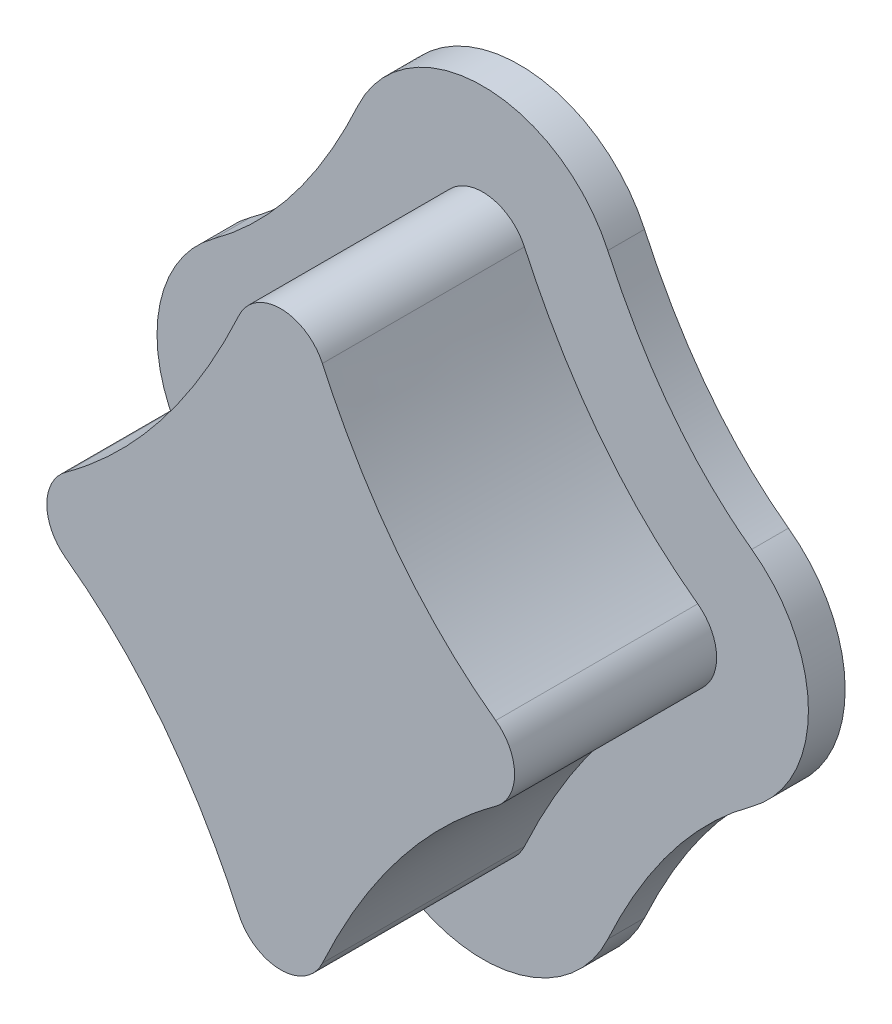
from build123d import *

# Parameters (mm, degrees)
BOSS_EXTRUDE1_DEPTH = 2.6
FILLET1_R           = 0.5
BOSS_EXTRUDE2_DEPTH = 0.4


with BuildPart() as part:
    # Sketch4 → Boss-Extrude1 (new body)
    with BuildSketch(Plane.XY):
        with BuildLine():
            add(Edge.make_bspline(
                [(0, 4), (0.515028324, 2.414905806), (1.36313107, 0.834026377), (3, 0)],
                knots=[0, 0, 0, 0, 1, 1, 1, 1], degree=3))
            add(Edge.make_bspline(
                [(0, -4), (0.515028324, -2.414905806), (1.36313107, -0.834026377), (3, 0)],
                knots=[0, 0, 0, 0, 1, 1, 1, 1], degree=3))
            add(Edge.make_bspline(
                [(0, -4), (-0.515028324, -2.414905806), (-1.36313107, -0.834026377), (-3, 0)],
                knots=[0, 0, 0, 0, 1, 1, 1, 1], degree=3))
            add(Edge.make_bspline(
                [(0, 4), (-0.515028324, 2.414905806), (-1.36313107, 0.834026377), (-3, 0)],
                knots=[0, 0, 0, 0, 1, 1, 1, 1], degree=3))
        make_face()
    extrude(amount=BOSS_EXTRUDE1_DEPTH)

    # Fillet1
    fillet1_edges = [part.edges().sort_by_distance(p)[0] for p in [
        (0, -4, 1.3),
        (-3, 0, 1.3),
        (3, 0, 1.3),
        (0, 4, 1.3),
    ]]
    fillet(fillet1_edges, radius=FILLET1_R)

    # Sketch5 → Boss-Extrude2 (add)
    with BuildSketch(Plane.XY):
        with BuildLine():
            ThreePointArc((-2.929739435, 1.212558746), (-3.546732478, 0), (-2.929739435, -1.212558746))
            add(Edge.make_bspline(
                [(-2.929739435, -1.212558746), (-2.754213175, -1.340380107), (-2.591067356, -1.481611947), (-2.286979377, -1.788126606), (-2.14580641, -1.953887397), (-1.757808942, -2.473821282), (-1.543643929, -2.852932461), (-1.361963313, -3.246613691)],
                knots=[0, 0, 0, 0, 0.25, 0.25, 0.5, 0.5, 1, 1, 1, 1], degree=3))
            ThreePointArc((-1.361963313, -3.246613691), (0, -4.118078938), (1.361963313, -3.246613691))
            add(Edge.make_bspline(
                [(1.361963313, -3.246613691), (1.543598049, -2.853031879), (1.757635539, -2.47411695), (2.274781933, -1.780991218), (2.578788315, -1.468127627), (2.929739435, -1.212558746)],
                knots=[0, 0, 0, 0, 0.5, 0.5, 1, 1, 1, 1], degree=3))
            ThreePointArc((2.929739435, -1.212558746), (3.546732478, 0), (2.929739435, 1.212558746))
            add(Edge.make_bspline(
                [(2.929739435, 1.212558746), (2.754213175, 1.340380107), (2.591067356, 1.481611947), (2.286979377, 1.788126606), (2.14580641, 1.953887397), (1.757808942, 2.473821282), (1.543643929, 2.852932461), (1.361963313, 3.246613691)],
                knots=[0, 0, 0, 0, 0.25, 0.25, 0.5, 0.5, 1, 1, 1, 1], degree=3))
            ThreePointArc((1.361963313, 3.246613691), (0, 4.118078938), (-1.361963313, 3.246613691))
            add(Edge.make_bspline(
                [(-1.361963313, 3.246613691), (-1.543598049, 2.853031879), (-1.757635539, 2.47411695), (-2.274781933, 1.780991218), (-2.578788315, 1.468127627), (-2.929739435, 1.212558746)],
                knots=[0, 0, 0, 0, 0.5, 0.5, 1, 1, 1, 1], degree=3))
        make_face()
    extrude(amount=BOSS_EXTRUDE2_DEPTH)


solid = part.part
